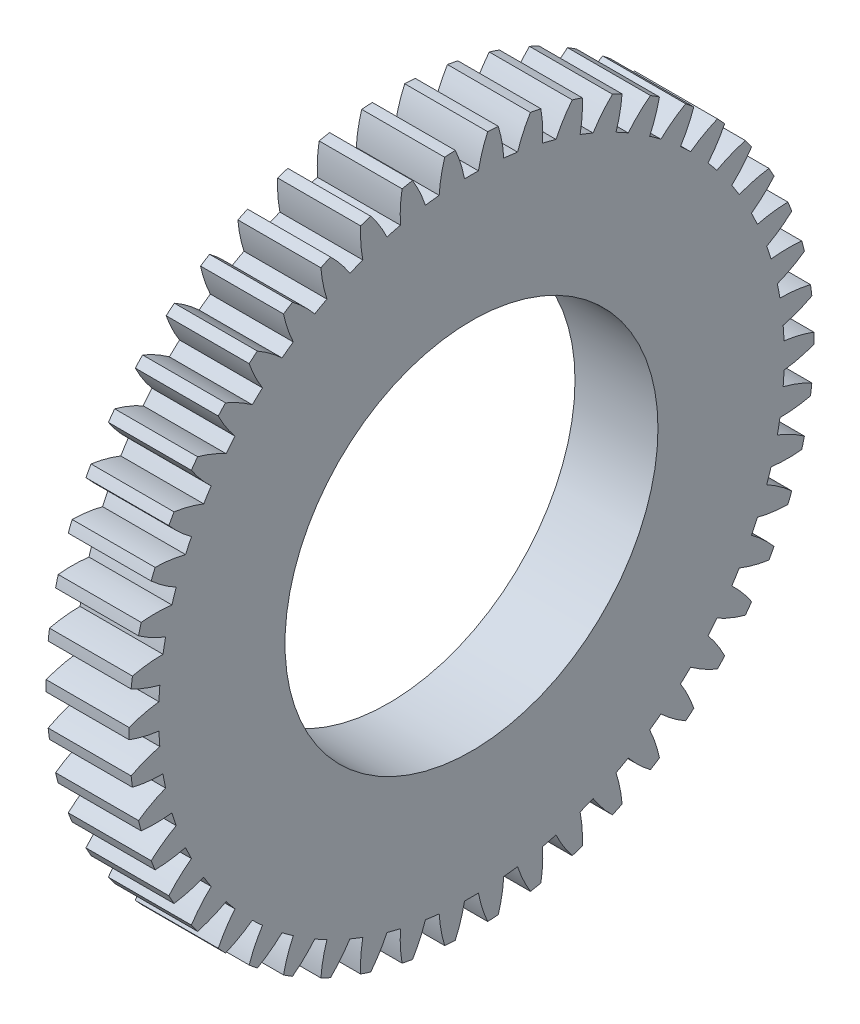
from build123d import *

# Parameters (mm, degrees)
BASPROSKE_W        = 20.000000005
BASPROSKE_H        = 82.55
TOOTHCUT_DEPTH     = 119.44410074
TEETHCUTS_COUNT    = 50
TEETHCUTS_ANGLE    = 352.8
BORSKE_R           = 0.396875
BORE_DEPTH         = 50.8000508
SKETCH1_R          = 44.958
CUT_EXTRUDE1_DEPTH = 20.32


with BuildPart() as part:
    # BasProSke → Base-Revolve (revolve)
    with BuildSketch(Plane(origin=(0, 0, 0), x_dir=(1, 0, 0), z_dir=(0, 1, 0)), mode=Mode.PRIVATE) as base_revolve_sk:
        with Locations((10.000000003, 41.275)):
            Rectangle(BASPROSKE_W, BASPROSKE_H)
    revolve(base_revolve_sk.sketch.rotate(Axis((-10, 0, 0), (1, 0, 0)), 180), axis=Axis((-10, 0, 0), (1, 0, 0)))

    # TooCutSke → ToothCut (cut, through all)
    with BuildSketch(Plane(origin=(0, 0, 0), x_dir=(0, 0, -1), z_dir=(1, 0, 0))):
        with BuildLine():
            ThreePointArc((1.678589432, 75.386294154), (0, 75.40498), (-1.678589432, 75.386294154))
            ThreePointArc((-1.678589432, 75.386294154), (-2.587590621, 79.000143923), (-3.91374857, 82.482599724))
            ThreePointArc((-3.91374857, 82.482599724), (0, 82.5754), (3.91374857, 82.482599724))
            ThreePointArc((3.91374857, 82.482599724), (2.587590621, 79.000143923), (1.678589432, 75.386294154))
        make_face()
    toothcut = extrude(amount=TOOTHCUT_DEPTH, mode=Mode.SUBTRACT)

    # TeethCuts: ToothCut ×50 about axis
    teethcuts_axis = Axis((-10, 0, 0), (1, 0, 0))
    for i in range(1, TEETHCUTS_COUNT):
        add(toothcut.rotate(teethcuts_axis, i * TEETHCUTS_ANGLE / (TEETHCUTS_COUNT - 1)), mode=Mode.SUBTRACT)

    # BorSke → Bore (cut, symmetric)
    with BuildSketch(Plane(origin=(0, 0, 0), x_dir=(0, 0, -1), z_dir=(1, 0, 0))):
        with Locations(Location((0, 0, 0), (0, 0, 180))):
            Circle(BORSKE_R)
    extrude(amount=BORE_DEPTH, both=True, mode=Mode.SUBTRACT)

    # Sketch1 → Cut-Extrude1 (cut)
    with BuildSketch(Plane(origin=(20.000000005, 0, 0), x_dir=(0, 0, -1), z_dir=(1, 0, 0))):
        Circle(SKETCH1_R)
    extrude(amount=-CUT_EXTRUDE1_DEPTH, mode=Mode.SUBTRACT)


solid = part.part
